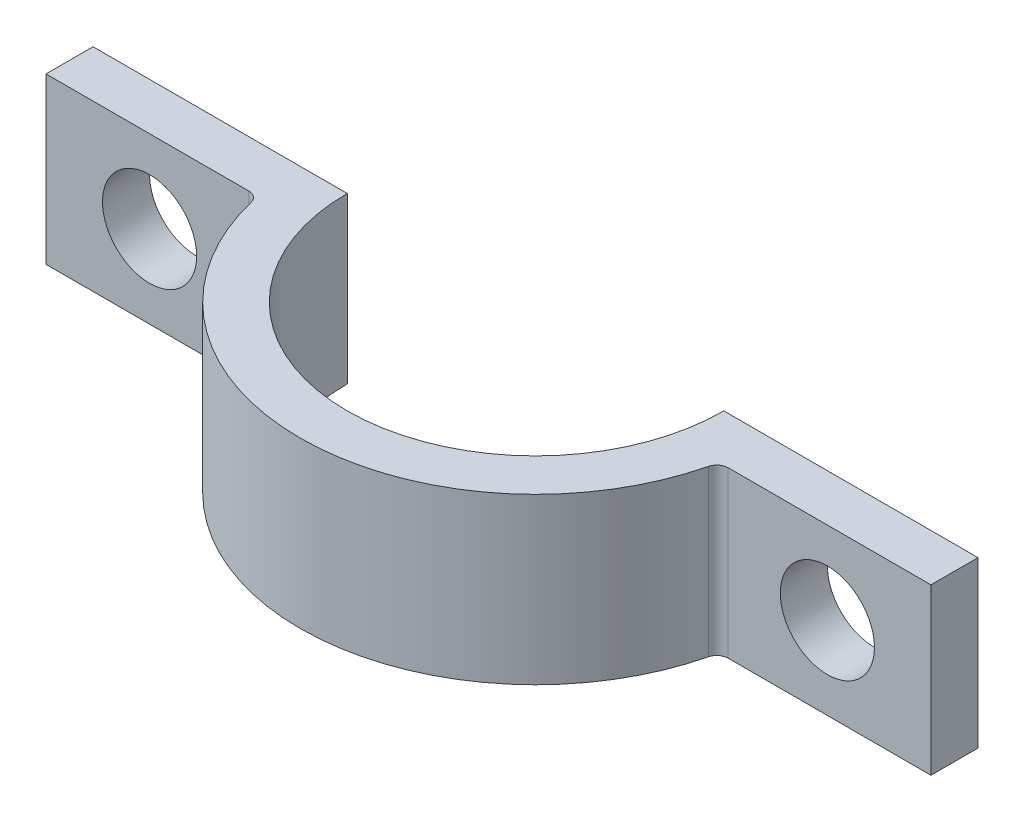
from build123d import *

# Parameters (mm, degrees)
BOSS_EXTRUDE1_DEPTH = 5.5626
SKETCH2_R           = 3.175
CUT_EXTRUDE1_DEPTH  = 4.175


with BuildPart() as part:
    # Sketch1 → Boss-Extrude1 (new body, symmetric)
    with BuildSketch(Plane(origin=(0, 0, 0), x_dir=(1, 0, 0), z_dir=(0, 1, 0))):
        with BuildLine():
            Line((-12.7, 0), (-29.845, 0))
            Line((-29.845, 0), (-29.845, -3.175))
            Line((-29.845, -3.175), (-16.164461018, -3.175))
            ThreePointArc((-16.164461018, -3.175), (-15.693695846, -3.337813758), (-15.424104025, -3.756679389))
            ThreePointArc((-15.424104025, -3.756679389), (0, -15.875), (15.424104025, -3.756679389))
            ThreePointArc((15.424104025, -3.756679389), (15.693695846, -3.337813758), (16.164461018, -3.175))
            Line((16.164461018, -3.175), (29.845, -3.175))
            Line((29.845, -3.175), (29.845, 0))
            Line((29.845, 0), (12.7, 0))
            ThreePointArc((12.7, 0), (0, -12.7), (-12.7, 0))
        make_face()
    extrude(amount=BOSS_EXTRUDE1_DEPTH, both=True)

    # Sketch2 → Cut-Extrude1 (cut, through all)
    with BuildSketch(Plane.XY.offset(3.175)):
        with Locations((-22.86, 0)):
            Circle(SKETCH2_R)
        with Locations((22.86, 0)):
            Circle(SKETCH2_R)
    extrude(amount=-CUT_EXTRUDE1_DEPTH, mode=Mode.SUBTRACT)


solid = part.part
